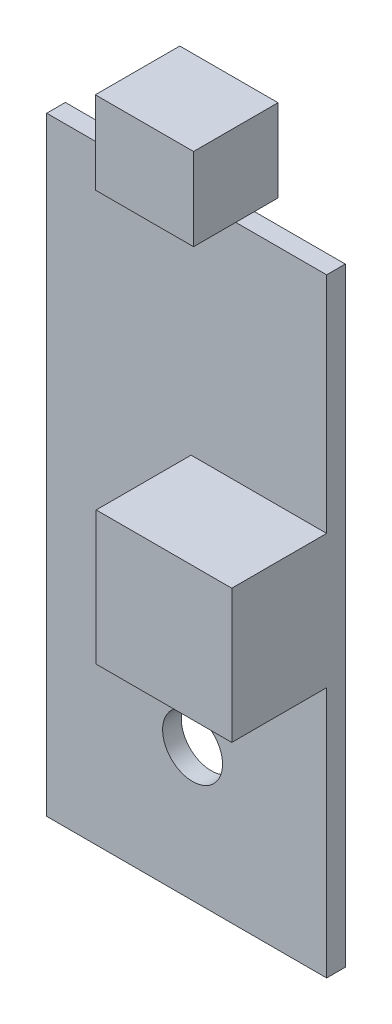
from build123d import *

# Parameters (mm, degrees)
BOSS_EXTRUDE1_DEPTH = 0.95
SKETCH1_4_W         = 5
SKETCH1_4_H         = 4.2
BOSS_EXTRUDE2_DEPTH = 2.15
SKETCH3_W           = 6.9
SKETCH3_H           = 6.8
BOSS_EXTRUDE3_DEPTH = 4.83
SKETCH4_R           = 1.525
CUT_EXTRUDE1_DEPTH  = 22.498477272


with BuildPart() as part:
    # Sketch1 → Boss-Extrude1 (new body)
    with BuildSketch(Plane.XY):
        Polygon((-2.5, 15.5), (-7.125, 15.5), (-7.125, -15.5), (7.125, -15.5), (7.125, 15.5), (2.5, 15.5), align=None)
    extrude(amount=-BOSS_EXTRUDE1_DEPTH)

    # Sketch1_4 → Boss-Extrude2 (add, symmetric)
    with BuildSketch(Plane.XY):
        with Locations((0, 17.6)):
            Rectangle(SKETCH1_4_W, SKETCH1_4_H)
    extrude(amount=BOSS_EXTRUDE2_DEPTH, both=True)

    # Sketch3 → Boss-Extrude3 (add)
    with BuildSketch(Plane.XY):
        with Locations((3.675, 0.7)):
            Rectangle(SKETCH3_W, SKETCH3_H)
    extrude(amount=BOSS_EXTRUDE3_DEPTH)

    # Sketch4 → Cut-Extrude1 (cut, through all)
    with BuildSketch(Plane.XY):
        with Locations((0.3, -8.725)):
            Circle(SKETCH4_R)
    extrude(amount=-CUT_EXTRUDE1_DEPTH, mode=Mode.SUBTRACT)


solid = part.part
